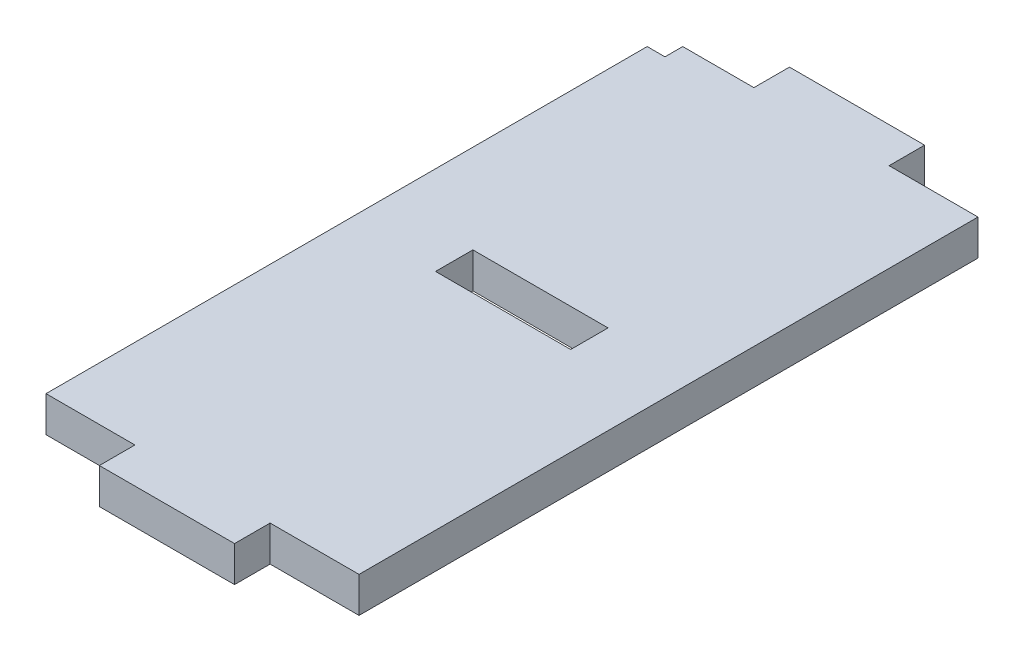
from build123d import *

# Parameters (mm, degrees)
SKETCH_1_W      = 7.6
SKETCH_1_H      = 2.1
EXTRUDE_1_DEPTH = 2


with BuildPart() as part:
    # 草图1 → 凸台-拉伸1 (new body)
    with BuildSketch(Plane(origin=(0, 0, 0), x_dir=(1, 0, 0), z_dir=(0, 1, 0))):
        Polygon((0, 33.8), (0, 0), (5, 0), (5, -2), (12.6, -2), (12.6, 0), (17.6, 0), (17.6, 34.8), (12.6, 34.8), (12.6, 36.8), (5, 36.8), (5, 34.8), (1, 34.8), (1, 33.8), align=None)
        with Locations((8.8, 17.95)):
            Rectangle(SKETCH_1_W, SKETCH_1_H, mode=Mode.SUBTRACT)
    extrude(amount=EXTRUDE_1_DEPTH)


solid = part.part
